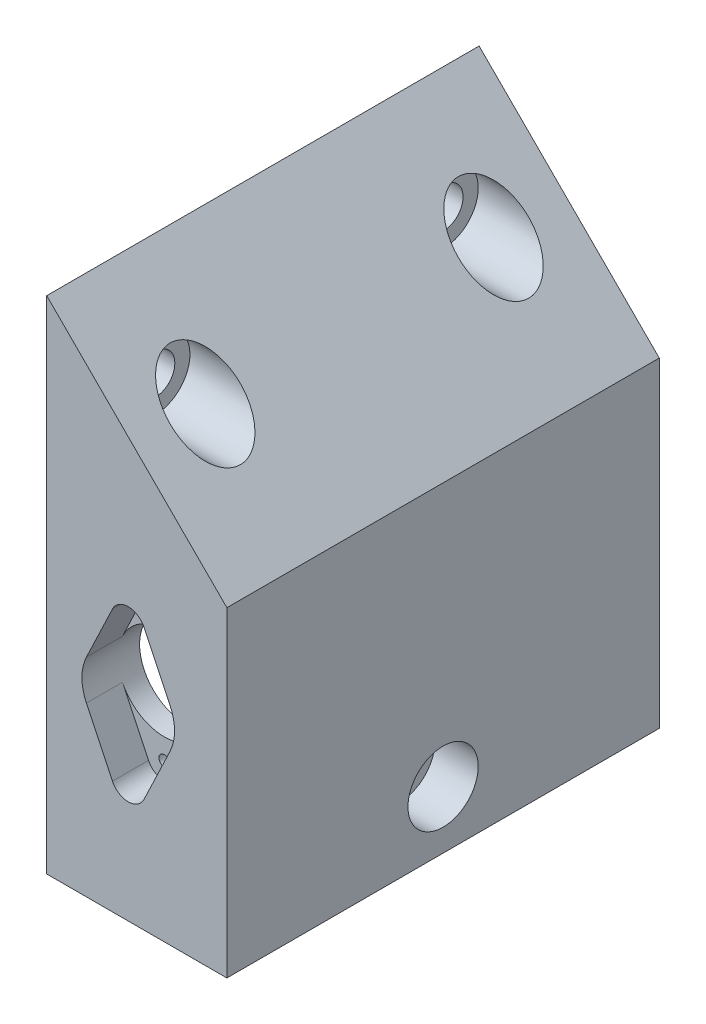
from build123d import *

# Parameters (mm, degrees)
SKETCH1_W           = 13.5
SKETCH1_H           = 29
BOSS_EXTRUDE1_DEPTH = 2
BOSS_EXTRUDE2_DEPTH = 56
BOSS_EXTRUDE3_DEPTH = 2
BOSS_EXTRUDE6_DEPTH = 23
SKETCH7_R           = 4.875
CUT_EXTRUDE2_DEPTH  = 6
BOSS_EXTRUDE7_REACH = 60
BOSS_EXTRUDE8_DEPTH = 6
CUT_EXTRUDE11_DEPTH = 5
SKETCH17_R          = 0.75
CUT_EXTRUDE13_DEPTH = 6
SKETCH18_R          = 6.425
CUT_EXTRUDE14_DEPTH = 6
SKETCH8_R           = 4.875
SKETCH8_R_2         = 2.775
CUT_EXTRUDE20_DEPTH = 20
SKETCH5_R           = 2.775
CUT_EXTRUDE21_DEPTH = 26
SKETCH19_R          = 2.775
CUT_EXTRUDE22_DEPTH = 26


with BuildPart() as part:
    # Sketch1 → Boss-Extrude1 (new body)
    with BuildSketch(Plane.XY):
        Polygon((23.484890655, 4.171572875), (0.484890655, 27.171572875), (0.484890655, -37.500000005), (23.484890655, -37.500000005), align=None)
        with Locations((11.635259587, -14.642279086)):
            Rectangle(SKETCH1_W, SKETCH1_H, mode=Mode.SUBTRACT)
        Polygon((23.484890655, 4.171572875), (23.484890655, -37.500000005), (0.484890655, -37.500000005), (0.484890655, -39.5), (25.484890655, -39.5), (25.484890655, 5), (0.484890655, 30), (0.484890655, 27.171572875), align=None)
    extrude(amount=BOSS_EXTRUDE1_DEPTH)

    # Sketch2 → Boss-Extrude2 (add)
    with BuildSketch(Plane.XY.offset(2)):
        Polygon((23.484890655, -37.500000005), (0.484890655, -37.500000005), (0.484890655, -39.5), (25.484890655, -39.5), (25.484890655, 5), (0.484890655, 30), (0.484890655, 27.171572875), (23.484890655, 4.171572875), align=None)
    extrude(amount=BOSS_EXTRUDE2_DEPTH)

    # Sketch3 → Boss-Extrude3 (add)
    with BuildSketch(Plane.XY.offset(58)):
        Polygon((25.484890655, 5), (0.484890655, 30), (0.484890655, -39.5), (25.484890655, -39.5), align=None)
    extrude(amount=BOSS_EXTRUDE3_DEPTH)

    # Sketch6 → Boss-Extrude6 (add)
    with BuildSketch(Plane.ZY.offset(-23.484890655)):
        with BuildLine():
            Line((37, -37.500000005), (37, -31.5))
            ThreePointArc((37, -31.5), (30, -24.5), (23, -31.5))
            Line((23, -31.5), (23, -37.500000005))
            Line((23, -37.500000005), (37, -37.500000005))
        make_face()
    extrude(amount=BOSS_EXTRUDE6_DEPTH)

    # Sketch7 → Cut-Extrude2 (cut)
    with BuildSketch(Plane(origin=(25.484890655, 0, 0), x_dir=(0, 0, -1), z_dir=(1, 0, 0))):
        with Locations((-30, -31.5)):
            Circle(SKETCH7_R)
    extrude(amount=-CUT_EXTRUDE2_DEPTH, mode=Mode.SUBTRACT)

    # Sketch9 → Boss-Extrude7 (add, up to next)
    with BuildSketch(Plane.XY.offset(2), mode=Mode.PRIVATE) as boss_extrude7_sk1:
        Polygon((0.484890655, 27.171572875), (17.541784111, 10.114679419), (0.484890655, 10.114679419), align=None)
    boss_extrude7_tool1 = extrude(boss_extrude7_sk1.sketch, amount=BOSS_EXTRUDE7_REACH, mode=Mode.PRIVATE) - part.part
    add(boss_extrude7_tool1.solids().sort_by_distance((6.170522, 15.800311, 2))[0])

    # Sketch14 → Boss-Extrude8 (add)
    with BuildSketch(Plane(origin=(0, 0, 58), x_dir=(-1, 0, 0), z_dir=(0, 0, -1))):
        Polygon((-17.541784111, 10.114679419), (-0.484890655, 10.114679419), (-0.484890655, -37.500000005), (-23.484890655, -37.500000005), (-23.484890655, 4.171572875), align=None)
    extrude(amount=BOSS_EXTRUDE8_DEPTH)

    # Sketch15 → Cut-Extrude11 (cut)
    with BuildSketch(Plane.XY.offset(60)):
        with BuildLine():
            Line((9.606797633, -3.100018288), (5.995686967, -10.67958818))
            ThreePointArc((5.995686967, -10.67958818), (5.371033475, -13.44302904), (5.995686967, -16.206469901))
            Line((5.995686967, -16.206469901), (9.606797633, -23.786039793))
            ThreePointArc((9.606797633, -23.786039793), (11.796033475, -25.16802904), (13.985269316, -23.786039793))
            Line((13.985269316, -23.786039793), (17.596379983, -16.206469901))
            ThreePointArc((17.596379983, -16.206469901), (18.221033475, -13.44302904), (17.596379983, -10.67958818))
            Line((17.596379983, -10.67958818), (13.985269316, -3.100018288))
            ThreePointArc((13.985269316, -3.100018288), (11.796033475, -1.71802904), (9.606797633, -3.100018288))
        make_face()
    extrude(amount=-CUT_EXTRUDE11_DEPTH, mode=Mode.SUBTRACT)

    # Sketch17 → Cut-Extrude13 (cut)
    with BuildSketch(Plane.XY.offset(55)):
        with Locations((11.796033475, -4.14302904)):
            Circle(SKETCH17_R)
        with Locations((11.796033475, -22.74302904)):
            Circle(SKETCH17_R)
    extrude(amount=-CUT_EXTRUDE13_DEPTH, mode=Mode.SUBTRACT)

    # Sketch18 → Cut-Extrude14 (cut)
    with BuildSketch(Plane.XY.offset(55)):
        with Locations((11.796033475, -13.44302904)):
            Circle(SKETCH18_R)
    extrude(amount=-CUT_EXTRUDE14_DEPTH, mode=Mode.SUBTRACT)

    # Sketch8 → Cut-Extrude20 (cut)
    with BuildSketch(Plane(origin=(25.484890655, 0, 0), x_dir=(0, 0, -1), z_dir=(1, 0, 0))):
        with Locations((-50, 18)):
            Circle(SKETCH8_R)
        with Locations((-50, 18)):
            Circle(SKETCH8_R_2, mode=Mode.SUBTRACT)
        with Locations((-10, 18)):
            Circle(SKETCH8_R)
        with Locations((-10, 18)):
            Circle(SKETCH8_R_2, mode=Mode.SUBTRACT)
    extrude(amount=-CUT_EXTRUDE20_DEPTH, mode=Mode.SUBTRACT)

    # Sketch5 → Cut-Extrude21 (cut, through all)
    with BuildSketch(Plane(origin=(25.484890655, 0, 0), x_dir=(0, 0, -1), z_dir=(1, 0, 0))):
        with Locations((-30, -31.5)):
            Circle(SKETCH5_R)
    extrude(amount=-CUT_EXTRUDE21_DEPTH, mode=Mode.SUBTRACT)

    # Sketch19 → Cut-Extrude22 (cut, through all)
    with BuildSketch(Plane(origin=(25.484890655, 0, 0), x_dir=(0, 0, -1), z_dir=(1, 0, 0))):
        with Locations((-50, 18)):
            Circle(SKETCH19_R)
        with Locations((-10, 18)):
            Circle(SKETCH19_R)
    extrude(amount=-CUT_EXTRUDE22_DEPTH, mode=Mode.SUBTRACT)


solid = part.part
